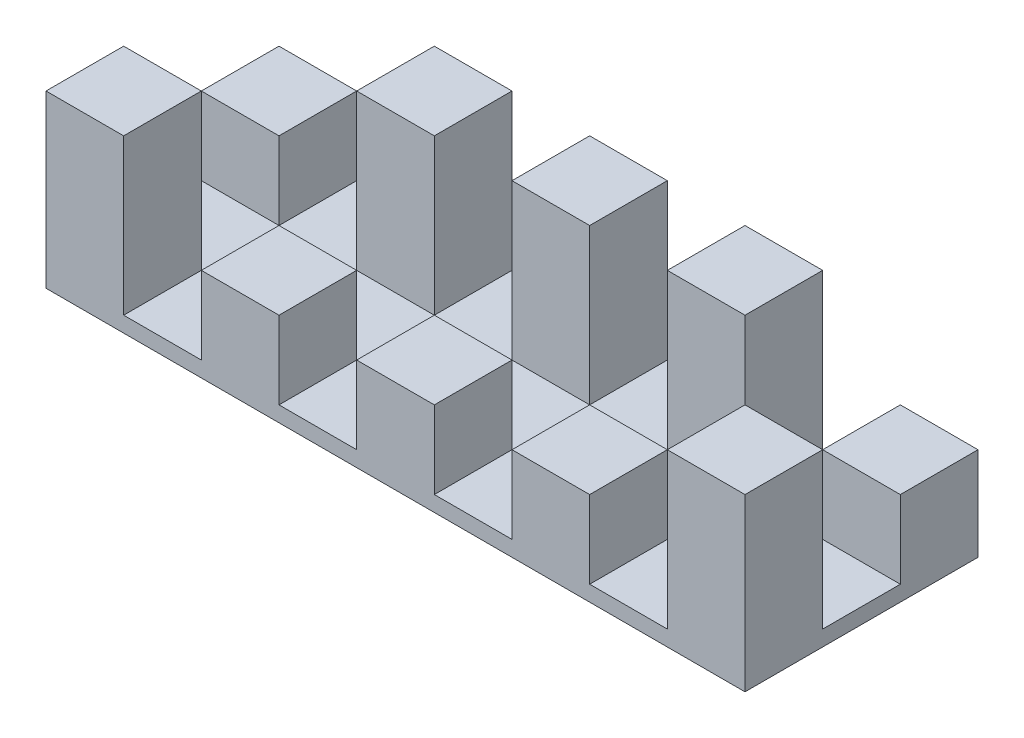
from build123d import *

# Parameters (mm, degrees)
SKETCH3_W           = 450
SKETCH3_H           = 150
BOSS_EXTRUDE1_DEPTH = 10
SKETCH12_W          = 50
SKETCH12_H          = 50
BOSS_EXTRUDE2_DEPTH = 50
SKETCH14_W          = 50
SKETCH14_H          = 50
BOSS_EXTRUDE3_DEPTH = 100


with BuildPart() as part:
    # Sketch3 → Boss-Extrude1 (new body)
    with BuildSketch(Plane(origin=(0, 0, 0), x_dir=(1, 0, 0), z_dir=(0, 1, 0))):
        Rectangle(SKETCH3_W, SKETCH3_H)
    extrude(amount=BOSS_EXTRUDE1_DEPTH)

    # Sketch12 → Boss-Extrude2 (add)
    with BuildSketch(Plane(origin=(0, 10, 0), x_dir=(1, 0, 0), z_dir=(0, 1, 0))):
        with Locations((0, -50)):
            Rectangle(SKETCH12_W, SKETCH12_H)
        with Locations((200, 50)):
            Rectangle(SKETCH12_W, SKETCH12_H)
        with Locations((100, -50)):
            Rectangle(SKETCH12_W, SKETCH12_H)
        with Locations((-200, 50)):
            Rectangle(SKETCH12_W, SKETCH12_H)
        with Locations((-100, -50)):
            Rectangle(SKETCH12_W, SKETCH12_H)
    extrude(amount=BOSS_EXTRUDE2_DEPTH)

    # Sketch14 → Boss-Extrude3 (add)
    with BuildSketch(Plane(origin=(0, 10, 0), x_dir=(1, 0, 0), z_dir=(0, 1, 0))):
        with Locations((-200, -50)):
            Rectangle(SKETCH14_W, SKETCH14_H)
        with Locations((200, -50)):
            Rectangle(SKETCH14_W, SKETCH14_H)
        with Locations((-100, 50)):
            Rectangle(SKETCH14_W, SKETCH14_H)
        with Locations((0, 50)):
            Rectangle(SKETCH14_W, SKETCH14_H)
        with Locations((100, 50)):
            Rectangle(SKETCH14_W, SKETCH14_H)
    extrude(amount=BOSS_EXTRUDE3_DEPTH)


solid = part.part
